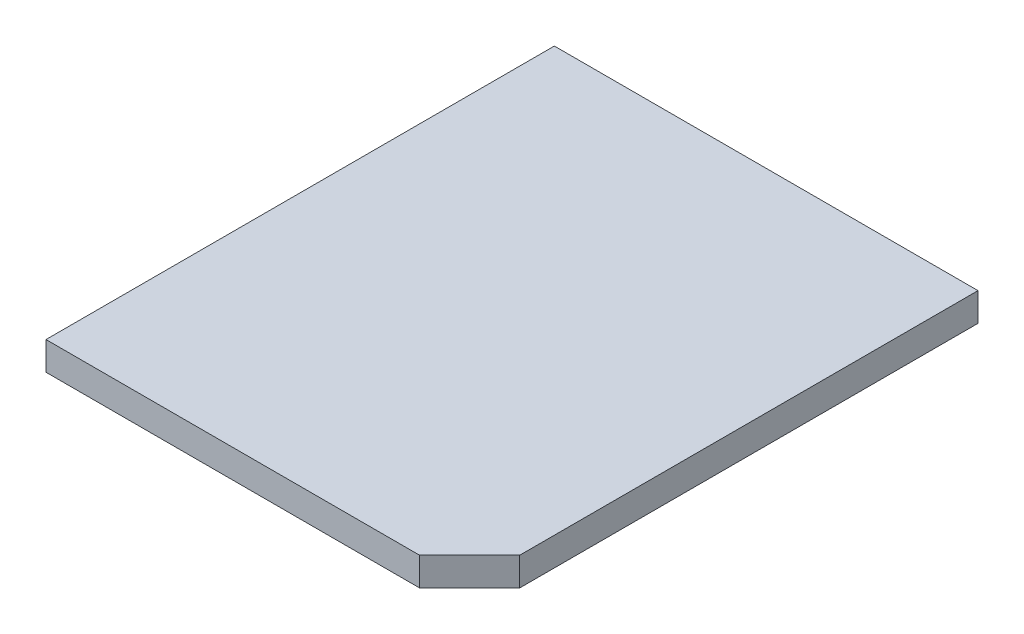
from build123d import *

# Parameters (mm, degrees)
SKETCH1_W           = 25.4
SKETCH1_H           = 30.48
BOSS_EXTRUDE1_DEPTH = 1.7
CHAMFER1_SIZE       = 3


with BuildPart() as part:
    # Sketch1 → Boss-Extrude1 (new body)
    with BuildSketch(Plane(origin=(0, 0, 0), x_dir=(1, 0, 0), z_dir=(0, 1, 0))):
        with Locations((12.7, 15.24)):
            Rectangle(SKETCH1_W, SKETCH1_H)
    extrude(amount=BOSS_EXTRUDE1_DEPTH)

    # Chamfer1
    chamfer1_edges = [part.edges().sort_by_distance(p)[0] for p in [
        (25.4, 0.85, 0),
    ]]
    chamfer(chamfer1_edges, length=CHAMFER1_SIZE)


solid = part.part
